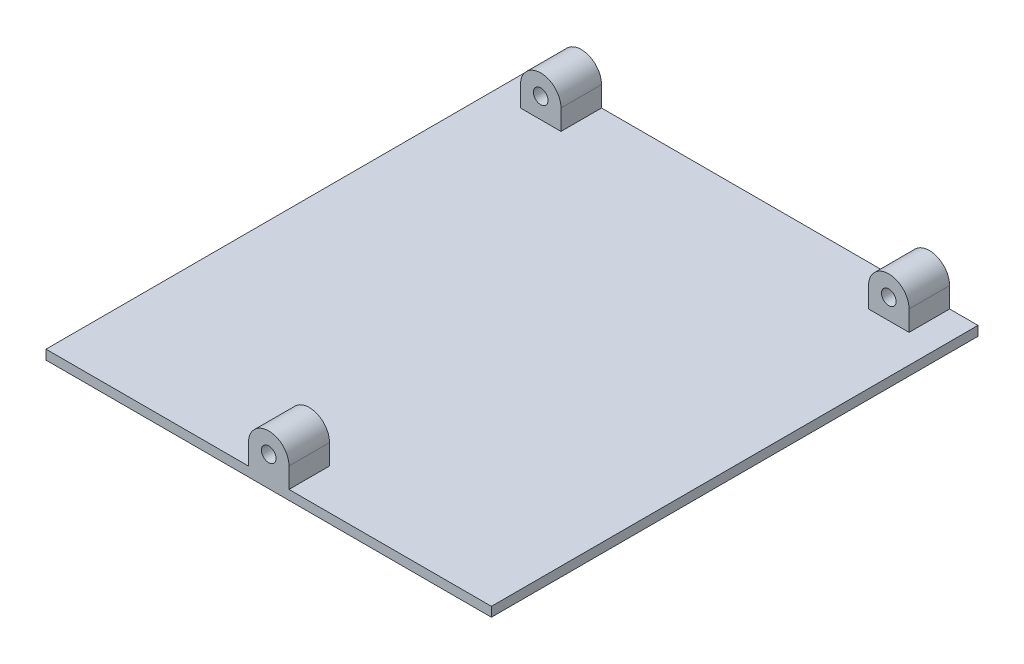
from build123d import *

# Parameters (mm, degrees)
SKETCH1_W           = 139.5
SKETCH1_H           = 152.4
BOSS_EXTRUDE1_DEPTH = 6.35
SKETCH2_W           = 139.5
SKETCH2_H           = 152.4
CUT_EXTRUDE1_DEPTH  = 3.375
SKETCH3_R           = 2.286
BOSS_EXTRUDE2_DEPTH = 12.7
SKETCH4_R           = 2.286
BOSS_EXTRUDE3_DEPTH = 12.7


with BuildPart() as part:
    # Sketch1 → Boss-Extrude1 (new body)
    with BuildSketch(Plane(origin=(0, 0, 0), x_dir=(1, 0, 0), z_dir=(0, 1, 0))):
        with Locations((69.75, 76.2)):
            Rectangle(SKETCH1_W, SKETCH1_H)
    extrude(amount=BOSS_EXTRUDE1_DEPTH)

    # Sketch2 → Cut-Extrude1 (cut)
    with BuildSketch(Plane(origin=(0, 6.35, 0), x_dir=(1, 0, 0), z_dir=(0, 1, 0))):
        with Locations((69.75, 76.2)):
            Rectangle(SKETCH2_W, SKETCH2_H)
    extrude(amount=-CUT_EXTRUDE1_DEPTH, mode=Mode.SUBTRACT)

    # Sketch3 → Boss-Extrude2 (add)
    with BuildSketch(Plane.XY):
        with BuildLine():
            Line((63.4, 9.325), (63.4, 2.975))
            Line((63.4, 2.975), (76.1, 2.975))
            Line((76.1, 2.975), (76.1, 9.325000158))
            ThreePointArc((76.1, 9.325000158), (69.749999921, 15.675000158), (63.4, 9.325))
        make_face()
        with Locations((69.75, 9.325000158)):
            Circle(SKETCH3_R, mode=Mode.SUBTRACT)
    extrude(amount=-BOSS_EXTRUDE2_DEPTH)

    # Sketch4 → Boss-Extrude3 (add)
    with BuildSketch(Plane(origin=(0, 0, -152.4), x_dir=(-1, 0, 0), z_dir=(0, 0, -1))):
        with BuildLine():
            Line((-130.61, 9.325), (-130.61, 2.975))
            Line((-130.61, 2.975), (-117.91, 2.975))
            Line((-117.91, 2.975), (-117.91, 9.325))
            ThreePointArc((-117.91, 9.325), (-124.26, 15.675), (-130.61, 9.325))
        make_face()
        with Locations((-124.26, 9.325)):
            Circle(SKETCH4_R, mode=Mode.SUBTRACT)
        with BuildLine():
            Line((-21.59, 9.325), (-21.59, 2.975))
            Line((-21.59, 2.975), (-8.89, 2.975))
            Line((-8.89, 2.975), (-8.89, 9.325))
            ThreePointArc((-8.89, 9.325), (-15.24, 15.675), (-21.59, 9.325))
        make_face()
        with Locations((-15.24, 9.325)):
            Circle(SKETCH4_R, mode=Mode.SUBTRACT)
    extrude(amount=-BOSS_EXTRUDE3_DEPTH)


solid = part.part
